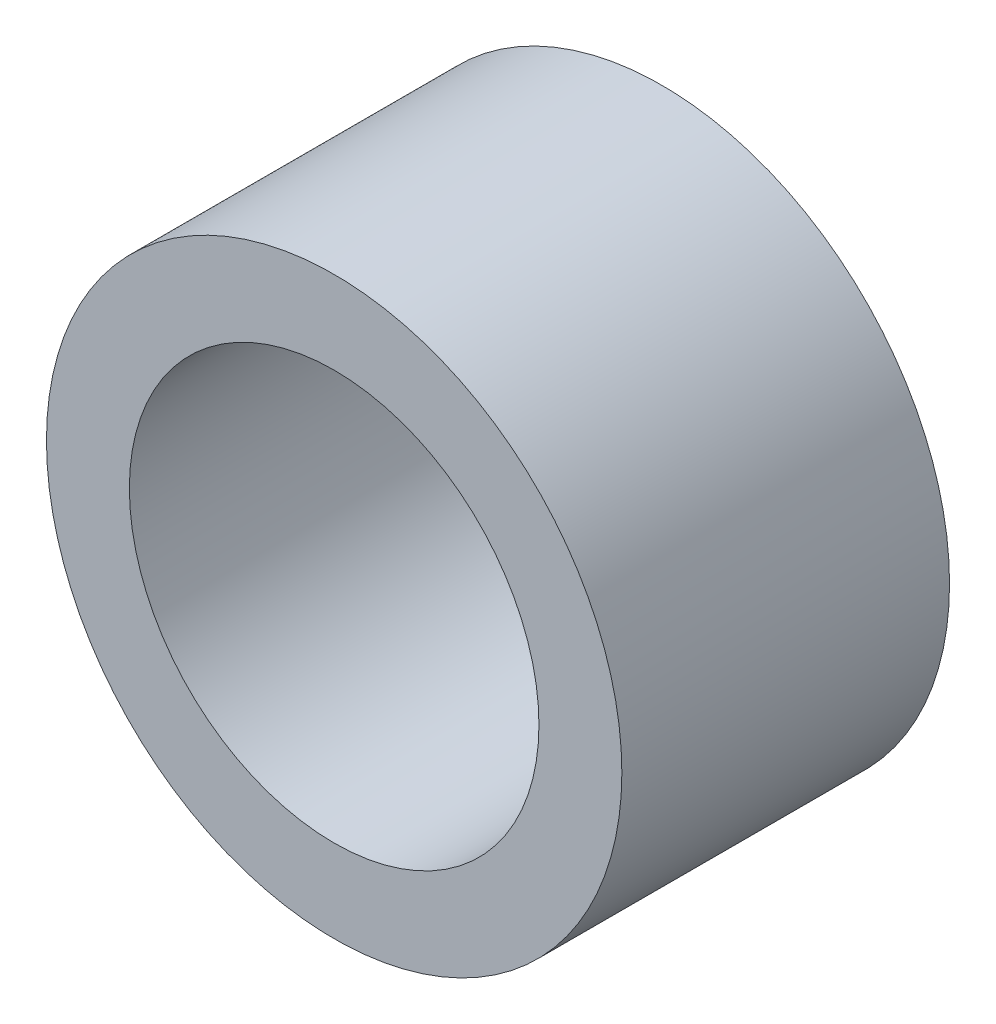
from build123d import *

# Parameters (mm, degrees)
SKETCH1_R      = 5.5753
SKETCH1_R_2    = 3.96875
EXTRUDE1_DEPTH = 3.175


with BuildPart() as part:
    # Sketch1 → Extrude1 (new body, symmetric)
    with BuildSketch(Plane.XY):
        Circle(SKETCH1_R)
        Circle(SKETCH1_R_2, mode=Mode.SUBTRACT)
    extrude(amount=EXTRUDE1_DEPTH, both=True)


solid = part.part
